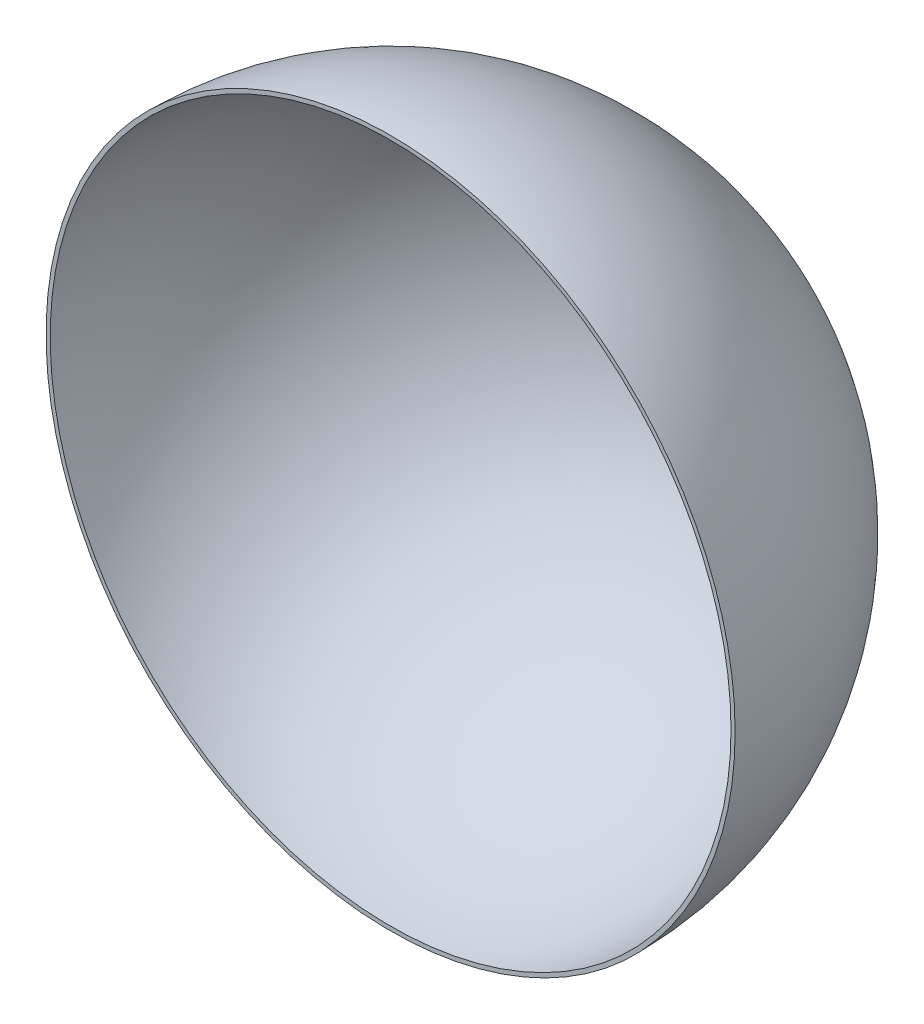
from build123d import *

# Parameters (mm, degrees)
ROTATION_D_NN1_ANGLE = 180


with BuildPart() as part:
    # Skizze1 → Rotation-Dünn1 (revolve)
    with BuildSketch(Plane.XY):
        with BuildLine():
            ThreePointArc((-250, 0), (0, -250), (250, 0))
            Line((250, 0), (247, 0))
            ThreePointArc((247, 0), (0, -247), (-247, 0))
            Line((-247, 0), (-250, 0))
        make_face()
    revolve(axis=Axis((-250, 0, 0), (1, 0, 0)), revolution_arc=ROTATION_D_NN1_ANGLE)


solid = part.part
